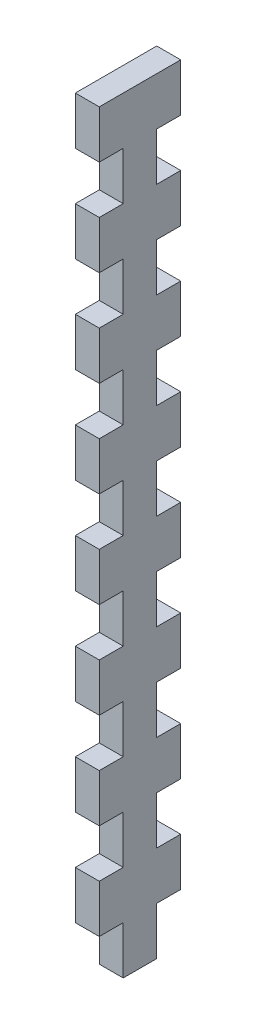
from build123d import *

# Parameters (mm, degrees)
SALIENTE_EXTRUIR1_DEPTH = 5


with BuildPart() as part:
    # Croquis1 → Saliente-Extruir1 (new body)
    with BuildSketch(Plane(origin=(0, 0, 0), x_dir=(0, 0, -1), z_dir=(1, 0, 0))):
        Polygon((-17.15051747, 72.789115646), (-17.15051747, 62.789115646), (-12.15051747, 62.789115646), (-12.15051747, 52.789115646), (-17.15051747, 52.789115646), (-17.15051747, 42.789115646), (-12.15051747, 42.789115646), (-12.15051747, 32.789115646), (-17.15051747, 32.789115646), (-17.15051747, 22.789115646), (-12.15051747, 22.789115646), (-12.15051747, 12.789115646), (-17.15051747, 12.789115646), (-17.15051747, 2.789115646), (-12.15051747, 2.789115646), (-12.15051747, -7.210884354), (-17.15051747, -7.210884354), (-17.15051747, -17.210884354), (-12.15051747, -17.210884354), (-12.15051747, -27.210884354), (-17.15051747, -27.210884354), (-17.15051747, -37.210884354), (-12.15051747, -37.210884354), (-12.15051747, -47.210884354), (-17.15051747, -47.210884354), (-17.15051747, -57.210884354), (-12.15051747, -57.210884354), (-12.15051747, -67.210884354), (-5.15051747, -67.210884354), (-5.15051747, -57.210884354), (-0.15051747, -57.210884354), (-0.15051747, -47.210884354), (-5.15051747, -47.210884354), (-5.15051747, -37.210884354), (-0.15051747, -37.210884354), (-0.15051747, -27.210884354), (-5.15051747, -27.210884354), (-5.15051747, -17.210884354), (-0.15051747, -17.210884354), (-0.15051747, -7.210884354), (-5.15051747, -7.210884354), (-5.15051747, 2.789115646), (-0.15051747, 2.789115646), (-0.15051747, 12.789115646), (-5.15051747, 12.789115646), (-5.15051747, 22.789115646), (-0.15051747, 22.789115646), (-0.15051747, 32.789115646), (-5.15051747, 32.789115646), (-5.15051747, 42.789115646), (-0.15051747, 42.789115646), (-0.15051747, 52.789115646), (-5.15051747, 52.789115646), (-5.15051747, 62.789115646), (-0.15051747, 62.789115646), (-0.15051747, 72.789115646), (-5.15051747, 72.789115646), (-5.15051747, 82.789115646), (-0.15051747, 82.789115646), (-0.15051747, 92.789115646), (-17.15051747, 92.789115646), (-17.15051747, 82.789115646), (-12.15051747, 82.789115646), (-12.15051747, 72.789115646), align=None)
    extrude(amount=SALIENTE_EXTRUIR1_DEPTH)


solid = part.part
